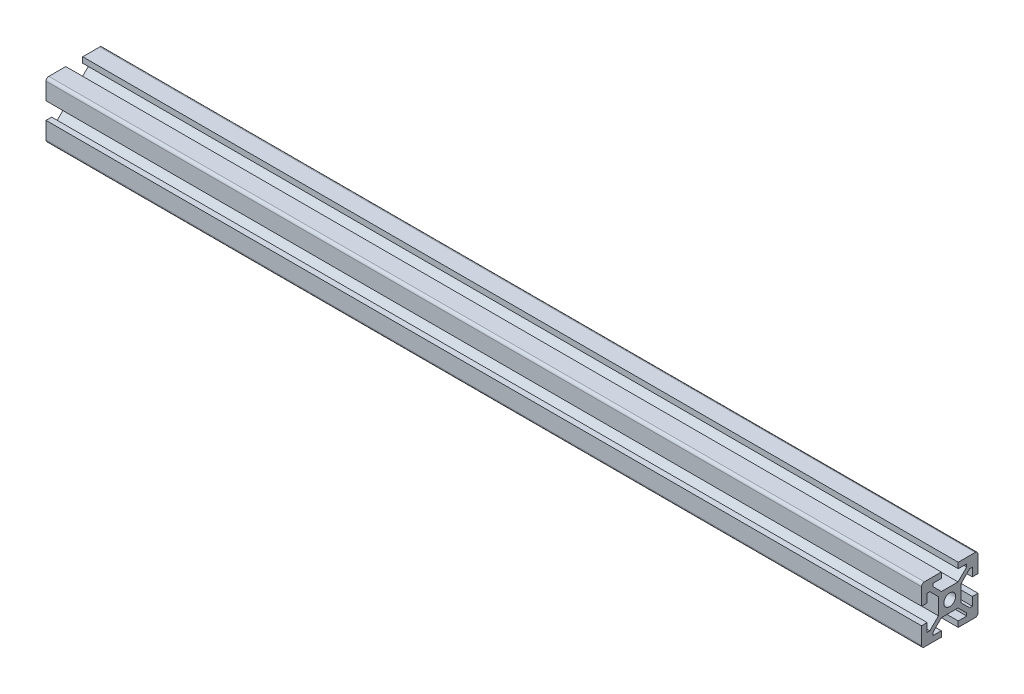
from build123d import *

# Parameters (mm, degrees)
SKETCH1_R           = 2.1
BOSS_EXTRUDE1_DEPTH = 310


with BuildPart() as part:
    # Sketch1 → Boss-Extrude1 (new body)
    with BuildSketch(Plane(origin=(0, 0, 0), x_dir=(0, 0, -1), z_dir=(1, 0, 0))):
        with BuildLine():
            Line((-10, 9), (-10, 3))
            Line((-10, 3), (-8, 3))
            Line((-8, 3), (-8, 6))
            Line((-8, 6), (-7.060660172, 6))
            Line((-7.060660172, 6), (-4, 2.939339828))
            Line((-4, 2.939339828), (-4, -2.939339828))
            Line((-4, -2.939339828), (-7.060660172, -6))
            Line((-7.060660172, -6), (-8, -6))
            Line((-8, -6), (-8, -3))
            Line((-8, -3), (-10, -3))
            Line((-10, -3), (-10, -9))
            ThreePointArc((-10, -9), (-9.707106781, -9.707106781), (-9, -10))
            Line((-9, -10), (-3, -10))
            Line((-3, -10), (-3, -8))
            Line((-3, -8), (-6, -8))
            Line((-6, -8), (-6, -7.060660172))
            Line((-6, -7.060660172), (-2.939339828, -4))
            Line((-2.939339828, -4), (2.939339828, -4))
            Line((2.939339828, -4), (6, -7.060660172))
            Line((6, -7.060660172), (6, -8))
            Line((6, -8), (3, -8))
            Line((3, -8), (3, -10))
            Line((3, -10), (9, -10))
            ThreePointArc((9, -10), (9.707106781, -9.707106781), (10, -9))
            Line((10, -9), (10, -3))
            Line((10, -3), (8, -3))
            Line((8, -3), (8, -6))
            Line((8, -6), (7.060660172, -6))
            Line((7.060660172, -6), (4, -2.939339828))
            Line((4, -2.939339828), (4, 2.939339828))
            Line((4, 2.939339828), (7.060660172, 6))
            Line((7.060660172, 6), (8, 6))
            Line((8, 6), (8, 3))
            Line((8, 3), (10, 3))
            Line((10, 3), (10, 9))
            ThreePointArc((10, 9), (9.707106781, 9.707106781), (9, 10))
            Line((9, 10), (3, 10))
            Line((3, 10), (3, 8))
            Line((3, 8), (6, 8))
            Line((6, 8), (6, 7.060660172))
            Line((6, 7.060660172), (2.939339828, 4))
            Line((2.939339828, 4), (-2.939339828, 4))
            Line((-2.939339828, 4), (-6, 7.060660172))
            Line((-6, 7.060660172), (-6, 8))
            Line((-6, 8), (-3, 8))
            Line((-3, 8), (-3, 10))
            Line((-3, 10), (-9, 10))
            ThreePointArc((-9, 10), (-9.707106781, 9.707106781), (-10, 9))
        make_face()
        Circle(SKETCH1_R, mode=Mode.SUBTRACT)
    extrude(amount=BOSS_EXTRUDE1_DEPTH)


solid = part.part
